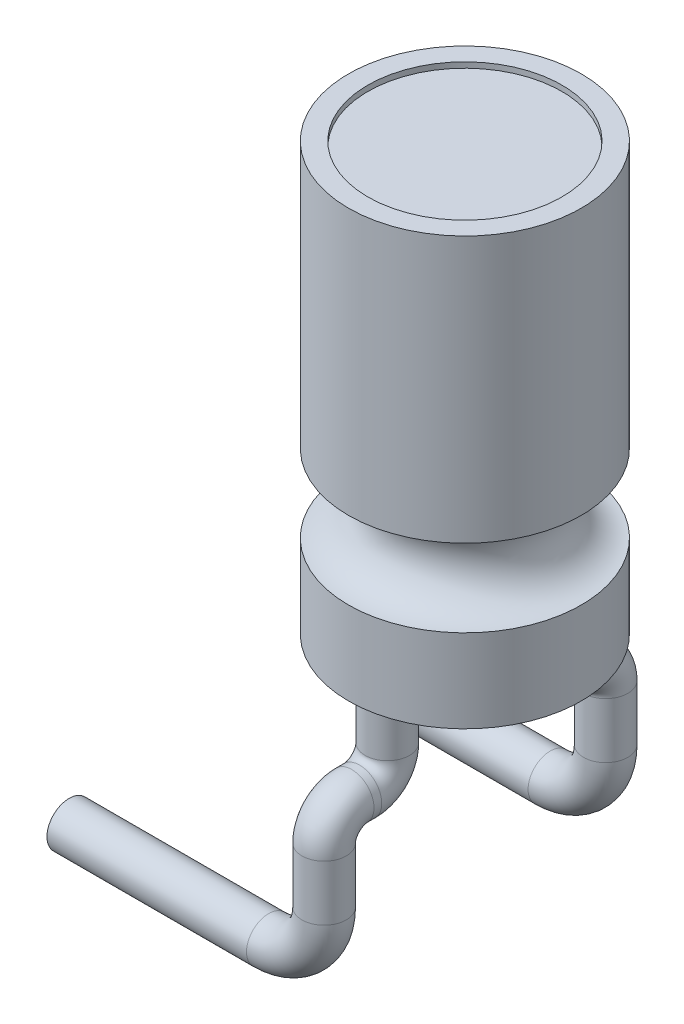
from build123d import *

# Parameters (mm, degrees)
ESQUISSE2_R             = 1.75
ENL_V_MAT_EXTRU_1_DEPTH = 0.1
ESQUISSE3_R             = 0.4
ESQUISSE5_R             = 0.4


with BuildPart() as part:
    # Esquisse1 → Révolution1 (revolve)
    with BuildSketch(Plane.XY, mode=Mode.PRIVATE) as r_volution1_sk:
        with BuildLine():
            Line((0, 35.216423663), (2.1, 35.216423663))
            Line((2.1, 35.216423663), (2.1, 30.416423663))
            ThreePointArc((2.1, 30.416423663), (1.4, 29.716423663), (2.1, 29.016423663))
            Line((2.1, 29.016423663), (2.1, 27.516423663))
            Line((2.1, 27.516423663), (0, 27.516423663))
            Line((0, 27.516423663), (0, 35.216423663))
        make_face()
    revolve(r_volution1_sk.sketch.rotate(Axis((0, 48.401709402, 0), (0, -1, 0)), 90), axis=Axis((0, 48.401709402, 0), (0, -1, 0)))  # turned: the seam where the file's is

    # Esquisse2 → Enlèv. mat.-Extru.1 (cut)
    with BuildSketch(Plane(origin=(0, 35.216423663, 0), x_dir=(-1, 0, 0), z_dir=(0, 1, 0))):
        with Locations(Location((0, 0, 0), (0, 0, 90))):  # turned: the seam where the file's is
            Circle(ESQUISSE2_R)
    extrude(amount=-ENL_V_MAT_EXTRU_1_DEPTH, mode=Mode.SUBTRACT)

    # Balayage1: sweep along a path in Esquisse4
    with BuildLine(Plane(origin=(0, 0, 0), x_dir=(0, 0, -1), z_dir=(1, 0, 0))) as balayage1_path:
        Line((-1.4, 27.516423663), (-1.4, 26.516423663))
        ThreePointArc((-1.4, 26.516423663), (-1.546446609, 26.162870273), (-1.9, 26.016423663))
        Line((-1.9, 26.016423663), (-2.04, 26.016423663))
        ThreePointArc((-2.04, 26.016423663), (-2.393553391, 25.869977054), (-2.54, 25.516423663))
    # Esquisse3 → Balayage1 (sweep)
    with BuildSketch(Plane.XZ.offset(-27.516423663)):
        with Locations((0, 1.4)):
            Circle(ESQUISSE3_R)
    balayage1 = sweep(path=balayage1_path.line)

    # Balayage2: sweep along a path in Esquisse6
    with BuildLine(Plane.XY.offset(2.54)) as balayage2_path:
        Line((0, 25.516423663), (0, 24.516423663))
        ThreePointArc((0, 24.516423663), (-0.292893219, 23.809316882), (-1, 23.516423663))
        Line((-1, 23.516423663), (-4.6, 23.516423663))
    # Esquisse5 → Balayage2 (sweep)
    with BuildSketch(Plane.XZ.offset(-25.516423663)):
        with Locations((0, 2.54)):
            Circle(ESQUISSE5_R)
    balayage2 = sweep(path=balayage2_path.line)

    # Symétrie1: Balayage1, Balayage2 across plane
    add(balayage1.mirror(Plane.XY))
    add(balayage2.mirror(Plane.XY))


solid = part.part
